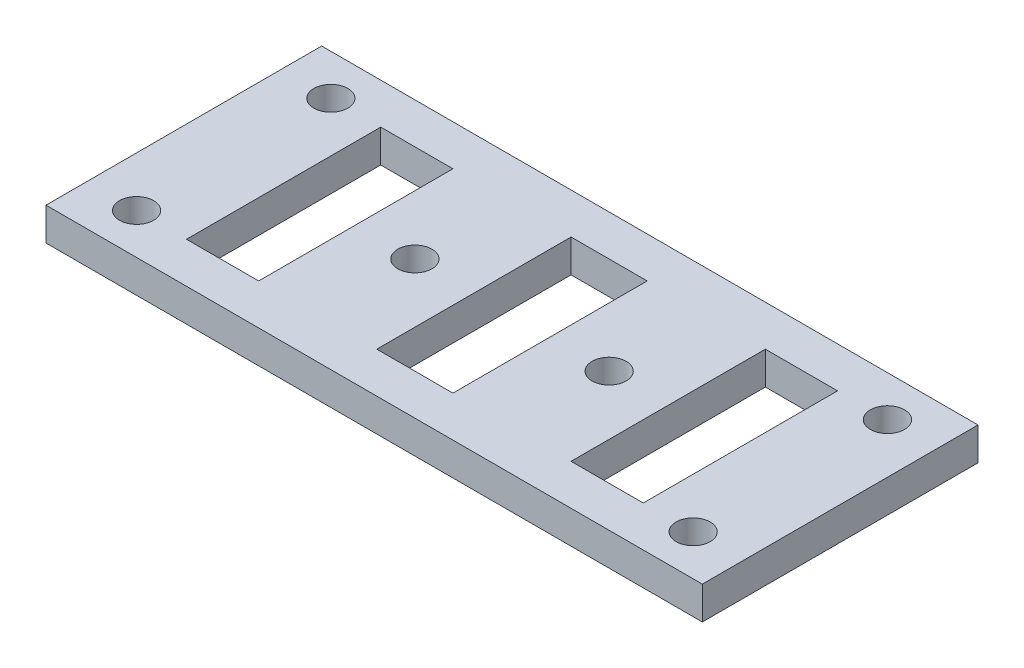
from build123d import *

# Parameters (mm, degrees)
SKETCH1_W           = 127
SKETCH1_H           = 53.34
SKETCH1_R           = 3.302
SKETCH1_W_2         = 13.97
SKETCH1_H_2         = 37.592
SKETCH1_W_3         = 14.732
BOSS_EXTRUDE1_DEPTH = 6.35


with BuildPart() as part:
    # Sketch1 → Boss-Extrude1 (new body)
    with BuildSketch(Plane(origin=(0, 0, 0), x_dir=(1, 0, 0), z_dir=(0, 1, 0))):
        with Locations((8.27250506, 9.271742923)):
            Rectangle(SKETCH1_W, SKETCH1_H)
        with Locations((-45.57549494, -9.524257077)):
            Circle(SKETCH1_R, mode=Mode.SUBTRACT)
        with Locations((-45.57549494, 28.067742923)):
            Circle(SKETCH1_R, mode=Mode.SUBTRACT)
        with Locations((62.12050506, -9.524257077)):
            Circle(SKETCH1_R, mode=Mode.SUBTRACT)
        with Locations((62.12050506, 28.067742923)):
            Circle(SKETCH1_R, mode=Mode.SUBTRACT)
        with Locations((-10.52349494, 9.271742923)):
            Circle(SKETCH1_R, mode=Mode.SUBTRACT)
        with Locations((27.06850506, 9.271742923)):
            Circle(SKETCH1_R, mode=Mode.SUBTRACT)
        with Locations((-28.93849494, 9.271742923)):
            Rectangle(SKETCH1_W_2, SKETCH1_H_2, mode=Mode.SUBTRACT)
        with Locations((45.48350506, 9.271742923)):
            Rectangle(SKETCH1_W_2, SKETCH1_H_2, mode=Mode.SUBTRACT)
        with Locations((8.27250506, 9.271742923)):
            Rectangle(SKETCH1_W_3, SKETCH1_H_2, mode=Mode.SUBTRACT)
    extrude(amount=BOSS_EXTRUDE1_DEPTH)


solid = part.part
